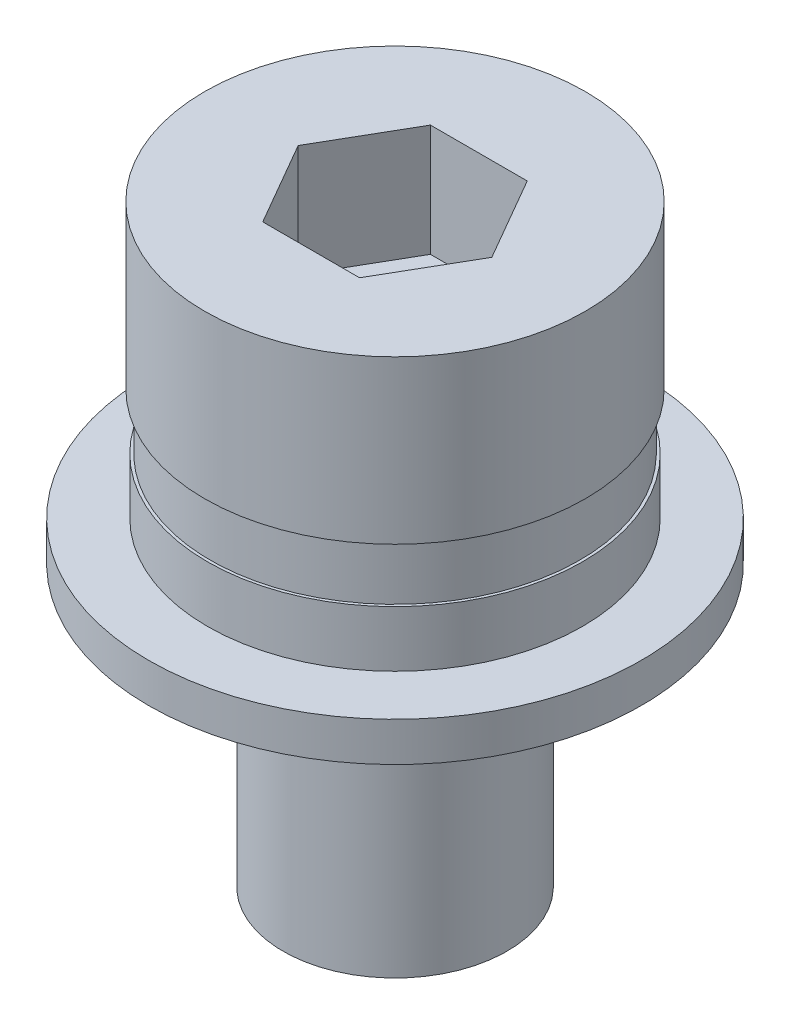
from build123d import *

# Parameters (mm, degrees)
SKETCH_1_R          = 4.4
EXTRUDE_1_DEPTH     = 0.7
SKETCH_2_R          = 3.35
EXTRUDE_2_DEPTH     = 1
SKETCH_3_R          = 3.4
EXTRUDE_3_DEPTH     = 3.9
SKETCH_4_R          = 10.526345736
SKETCH_4_R_2        = 3.3
CUT_EXTRUDE_1_DEPTH = 1
CUT_EXTRUDE_2_DEPTH = 2
SKETCH_6_R          = 2
EXTRUDE_4_DEPTH     = 5


with BuildPart() as part:
    # 草图1 → 凸台-拉伸1 (new body)
    with BuildSketch(Plane(origin=(0, 0, 0), x_dir=(1, 0, 0), z_dir=(0, 1, 0))):
        Circle(SKETCH_1_R)
    extrude(amount=EXTRUDE_1_DEPTH)

    # 草图2 → 凸台-拉伸2 (add)
    with BuildSketch(Plane(origin=(0, 0.7, 0), x_dir=(1, 0, 0), z_dir=(0, 1, 0))):
        Circle(SKETCH_2_R)
    extrude(amount=EXTRUDE_2_DEPTH)

    # 草图3 → 凸台-拉伸3 (add)
    with BuildSketch(Plane(origin=(0, 1.7, 0), x_dir=(1, 0, 0), z_dir=(0, 1, 0))):
        Circle(SKETCH_3_R)
    extrude(amount=EXTRUDE_3_DEPTH)

    # 草图4 → 切除-拉伸1 (cut)
    with BuildSketch(Plane.XZ.offset(-1.7)):
        Circle(SKETCH_4_R)
        Circle(SKETCH_4_R_2, mode=Mode.SUBTRACT)
    extrude(amount=-CUT_EXTRUDE_1_DEPTH, mode=Mode.SUBTRACT)

    # 草图5 → 切除-拉伸2 (cut)
    with BuildSketch(Plane(origin=(0, 5.6, 0), x_dir=(1, 0, 0), z_dir=(0, 1, 0))):
        Polygon((-1.729316128, 0), (-0.864658064, -1.497631698), (0.864658064, -1.497631698), (1.729316128, 0), (0.864658064, 1.497631698), (-0.864658064, 1.497631698), align=None)
    extrude(amount=-CUT_EXTRUDE_2_DEPTH, mode=Mode.SUBTRACT)

    # 草图6 → 凸台-拉伸4 (add)
    with BuildSketch(Plane.XZ):
        Circle(SKETCH_6_R)
    extrude(amount=EXTRUDE_4_DEPTH)


solid = part.part
